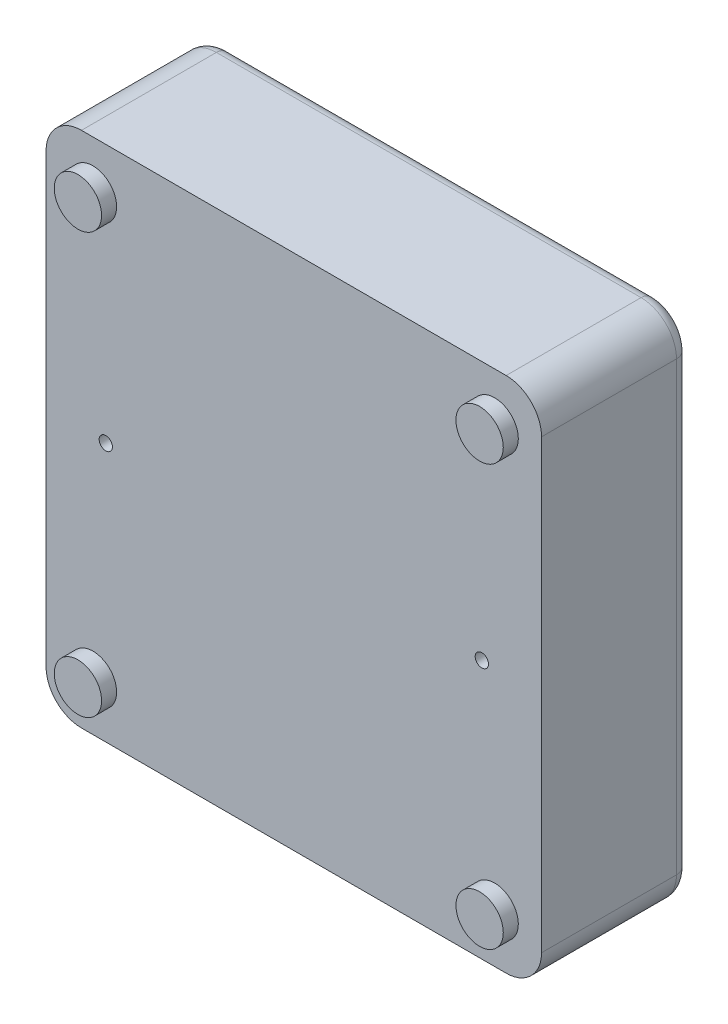
from build123d import *

# Parameters (mm, degrees)
SKETCH_1_W          = 112
SKETCH_1_H          = 117
EXTRUDE_1_DEPTH     = 33.5
FILLET_1_R          = 8
SKETCH_2_R          = 1.5
CUT_EXTRUDE_1_DEPTH = 3
SKETCH_3_R          = 5.35
EXTRUDE_2_DEPTH     = 3.4
FILLET_2_R          = 3


with BuildPart() as part:
    # 草图1 → 凸台-拉伸1 (new body)
    with BuildSketch(Plane.XY):
        with Locations((-117.832945126, 6.678161232)):
            Rectangle(SKETCH_1_W, SKETCH_1_H)
    extrude(amount=EXTRUDE_1_DEPTH)

    # 圆角1
    fillet_1_edges = [part.edges().sort_by_distance(p)[0] for p in [
        (-173.832945126, 65.178161232, 16.75),
        (-61.832945126, 65.178161232, 16.75),
        (-61.832945126, -51.821838768, 16.75),
        (-173.832945126, -51.821838768, 16.75),
    ]]
    fillet(fillet_1_edges, radius=FILLET_1_R)

    # 草图2 → 切除-拉伸1 (cut)
    with BuildSketch(Plane.XY.offset(33.5)):
        with Locations((-75.332945126, 6.678161232)):
            Circle(SKETCH_2_R)
        with Locations((-160.332945126, 6.678161232)):
            Circle(SKETCH_2_R)
    extrude(amount=-CUT_EXTRUDE_1_DEPTH, mode=Mode.SUBTRACT)

    # 草图3 → 凸台-拉伸2 (add)
    with BuildSketch(Plane.XY.offset(33.5)):
        with Locations((-72.432945126, -40.821838768)):
            Circle(SKETCH_3_R)
        with Locations((-163.232945126, -40.821838768)):
            Circle(SKETCH_3_R)
        with Locations((-163.232945126, 54.178161232)):
            Circle(SKETCH_3_R)
        with Locations((-72.432945126, 54.178161232)):
            Circle(SKETCH_3_R)
    extrude(amount=EXTRUDE_2_DEPTH)

    # 圆角2
    fillet_2_edges = [part.edges().sort_by_distance(p)[0] for p in [
        (-117.832945126, 65.178161232, 0),
        (-173.832945126, 6.678161232, 0),
        (-61.832945126, 6.678161232, 0),
        (-117.832945126, -51.821838768, 0),
        (-64.176090876, -49.478693018, 0),
        (-171.489799375, -49.478693018, 0),
        (-171.489799375, 62.835015481, 0),
        (-64.176090876, 62.835015481, 0),
    ]]
    fillet(fillet_2_edges, radius=FILLET_2_R)


solid = part.part
